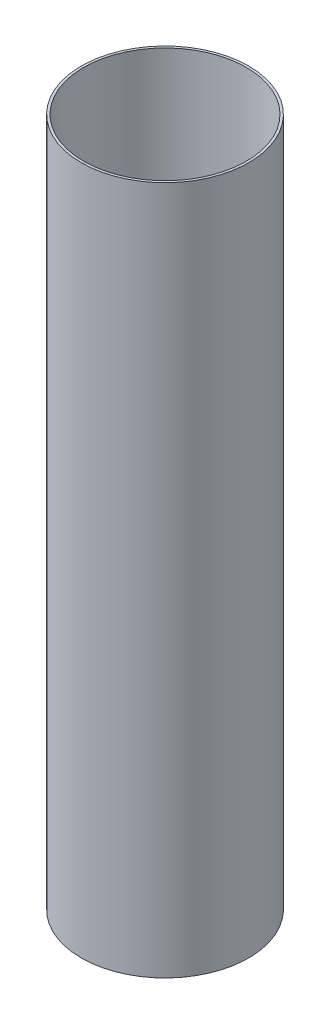
from build123d import *

# Parameters (mm, degrees)
MOTOR_MOUNT_PROFILE_SKETCH_R   = 50.9778
MOTOR_MOUNT_PROFILE_SKETCH_R_2 = 49.53
MOTOR_MOUNT_BODY_DEPTH         = 419.351


with BuildPart() as part:
    # Motor Mount Profile Sketch → Motor Mount Body (new body)
    with BuildSketch(Plane(origin=(0, 0, 0), x_dir=(1, 0, 0), z_dir=(0, 1, 0))):
        Circle(MOTOR_MOUNT_PROFILE_SKETCH_R)
        Circle(MOTOR_MOUNT_PROFILE_SKETCH_R_2, mode=Mode.SUBTRACT)
    extrude(amount=MOTOR_MOUNT_BODY_DEPTH)


solid = part.part
